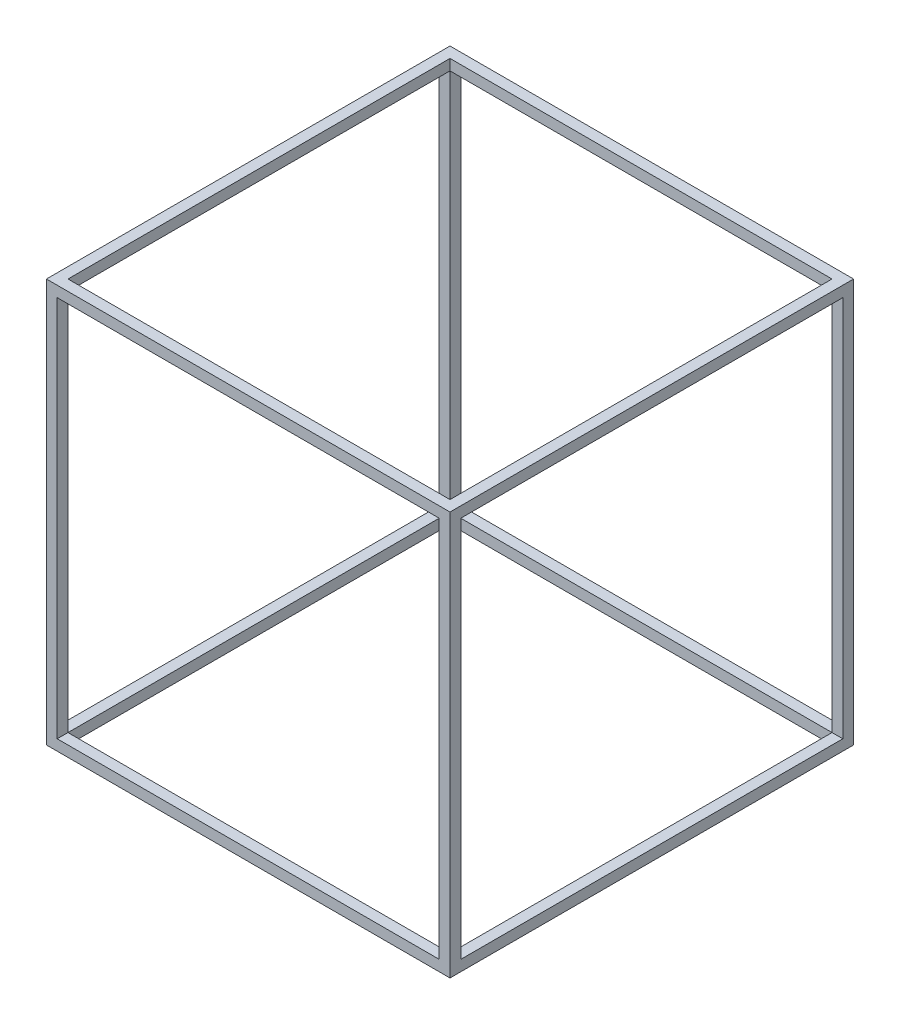
from build123d import *

# Parameters (mm, degrees)
SKETCH1_W           = 750
SKETCH1_H           = 750
SKETCH1_W_2         = 710
SKETCH1_H_2         = 710
BOSS_EXTRUDE1_DEPTH = 20
SKETCH2_W           = 20
SKETCH2_H           = 20
BOSS_EXTRUDE2_DEPTH = 710
SKETCH3_W           = 710
SKETCH3_H           = 710
BOSS_EXTRUDE3_DEPTH = 20


with BuildPart() as part:
    # Sketch1 → Boss-Extrude1 (new body)
    with BuildSketch(Plane(origin=(0, 0, 0), x_dir=(1, 0, 0), z_dir=(0, 1, 0))):
        with Locations((375, 375)):
            Rectangle(SKETCH1_W, SKETCH1_H)
        with Locations((375, 375)):
            Rectangle(SKETCH1_W_2, SKETCH1_H_2, mode=Mode.SUBTRACT)
    extrude(amount=BOSS_EXTRUDE1_DEPTH)

    # Sketch2 → Boss-Extrude2 (add)
    with BuildSketch(Plane(origin=(0, 20, 0), x_dir=(1, 0, 0), z_dir=(0, 1, 0))):
        with Locations((10, 740)):
            Rectangle(SKETCH2_W, SKETCH2_H)
        with Locations((740, 740)):
            Rectangle(SKETCH2_W, SKETCH2_H)
        with Locations((10, 10)):
            Rectangle(SKETCH2_W, SKETCH2_H)
        with Locations((740, 10)):
            Rectangle(SKETCH2_W, SKETCH2_H)
    extrude(amount=BOSS_EXTRUDE2_DEPTH)

    # Sketch3 → Boss-Extrude3 (add)
    with BuildSketch(Plane(origin=(0, 730, 0), x_dir=(1, 0, 0), z_dir=(0, 1, 0))):
        Polygon((730, 750), (20, 750), (0, 750), (0, 730), (0, 20), (0, 0), (20, 0), (730, 0), (750, 0), (750, 20), (750, 730), (750, 750), align=None)
        with Locations((375, 375)):
            Rectangle(SKETCH3_W, SKETCH3_H, mode=Mode.SUBTRACT)
    extrude(amount=BOSS_EXTRUDE3_DEPTH)


solid = part.part
